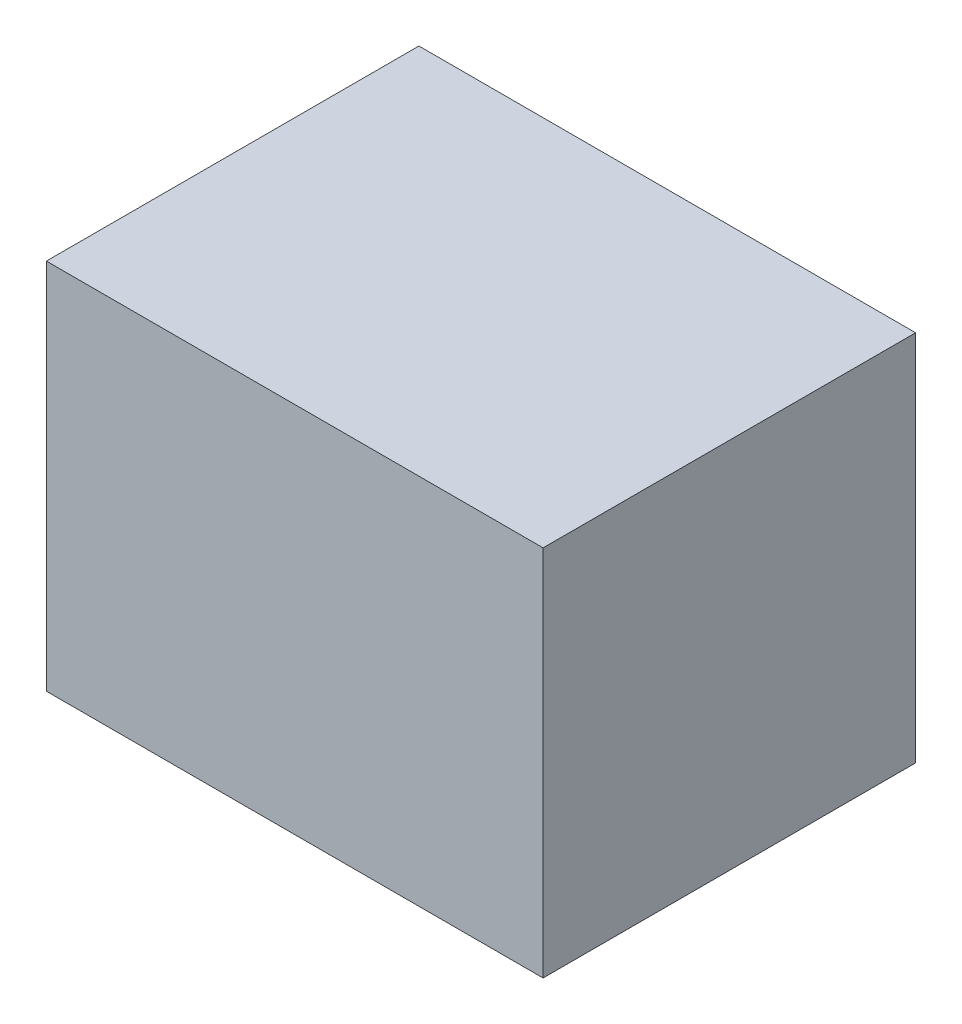
from build123d import *

# Parameters (mm, degrees)
SKETCH1_W           = 9.525
SKETCH1_H           = 9.525
BOSS_EXTRUDE1_DEPTH = 6.35


with BuildPart() as part:
    # Sketch1 → Boss-Extrude1 (new body, symmetric)
    with BuildSketch(Plane(origin=(0, 0, 0), x_dir=(0, 0, -1), z_dir=(1, 0, 0))):
        with Locations((-4.7625, 4.7625)):
            Rectangle(SKETCH1_W, SKETCH1_H)
    extrude(amount=BOSS_EXTRUDE1_DEPTH, both=True)


solid = part.part
